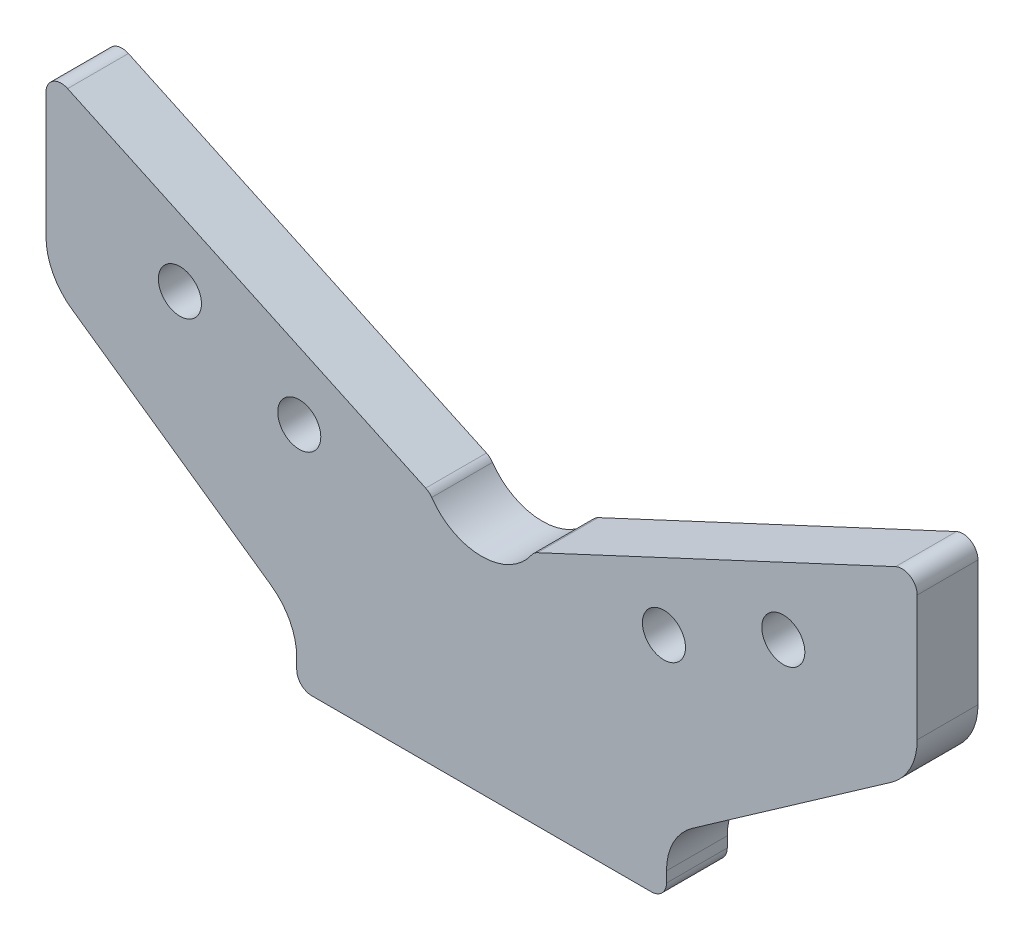
from build123d import *

# Parameters (mm, degrees)
EXTRUDE1_DEPTH         = 12
M10_GEVINDHULLER_D     = 8.5
M10_GEVINDHULLER_DEPTH = 22
M10_GEVINDHULLER_TIP   = 2.553657631


with BuildPart() as part:
    # Sketch1 → Extrude1 (new body)
    with BuildSketch(Plane.XY):
        with BuildLine():
            Line((36.5, 3), (36.5, 5.092922252))
            ThreePointArc((36.5, 5.092922252), (37.855870002, 10.633905611), (41.617082764, 14.922746783))
            Line((41.617082764, 14.922746783), (80.882917236, 42.416980075))
            ThreePointArc((80.882917236, 42.416980075), (84.644129998, 46.705821248), (86, 52.246804607))
            Line((86, 52.246804607), (86, 77))
            ThreePointArc((86, 77), (84.611898825, 79.530174337), (81.732145215, 79.718923361))
            Line((81.732145215, 79.718923361), (11.04340479, 46.756222356))
            ThreePointArc((11.04340479, 46.756222356), (10.379689702, 46.332737476), (9.84900766, 45.751158822))
            ThreePointArc((9.84900766, 45.751158822), (0, 40.60659813), (-9.84900766, 45.751158822))
            ThreePointArc((-9.84900766, 45.751158822), (-10.379689702, 46.332737476), (-11.04340479, 46.756222356))
            Line((-11.04340479, 46.756222356), (-81.732145215, 79.718923361))
            ThreePointArc((-81.732145215, 79.718923361), (-84.611898825, 79.530174337), (-86, 77))
            Line((-86, 77), (-86, 52.246804607))
            ThreePointArc((-86, 52.246804607), (-84.644129998, 46.705821248), (-80.882917236, 42.416980075))
            Line((-80.882917236, 42.416980075), (-41.617082764, 14.922746783))
            ThreePointArc((-41.617082764, 14.922746783), (-37.855870002, 10.633905611), (-36.5, 5.092922252))
            Line((-36.5, 5.092922252), (-36.5, 3))
            ThreePointArc((-36.5, 3), (-35.621320344, 0.878679656), (-33.5, 0))
            Line((-33.5, 0), (0, 0))
            Line((0, 0), (33.5, 0))
            ThreePointArc((33.5, 0), (35.621320344, 0.878679656), (36.5, 3))
        make_face()
    extrude(amount=EXTRUDE1_DEPTH)

    # M10 gevindhuller
    with Locations(Plane.XY.offset(12)):
        with Locations((-59.564002463, 56.141213601), (-36, 45.153138796), (59.564002463, 56.141213601), (36, 45.153138796)):
            Hole(M10_GEVINDHULLER_D / 2, depth=M10_GEVINDHULLER_DEPTH)
            with Locations((0, 0, -(M10_GEVINDHULLER_DEPTH + M10_GEVINDHULLER_TIP / 2))):  # 118° drill point
                Cone(0, M10_GEVINDHULLER_D / 2, M10_GEVINDHULLER_TIP, mode=Mode.SUBTRACT)


solid = part.part
